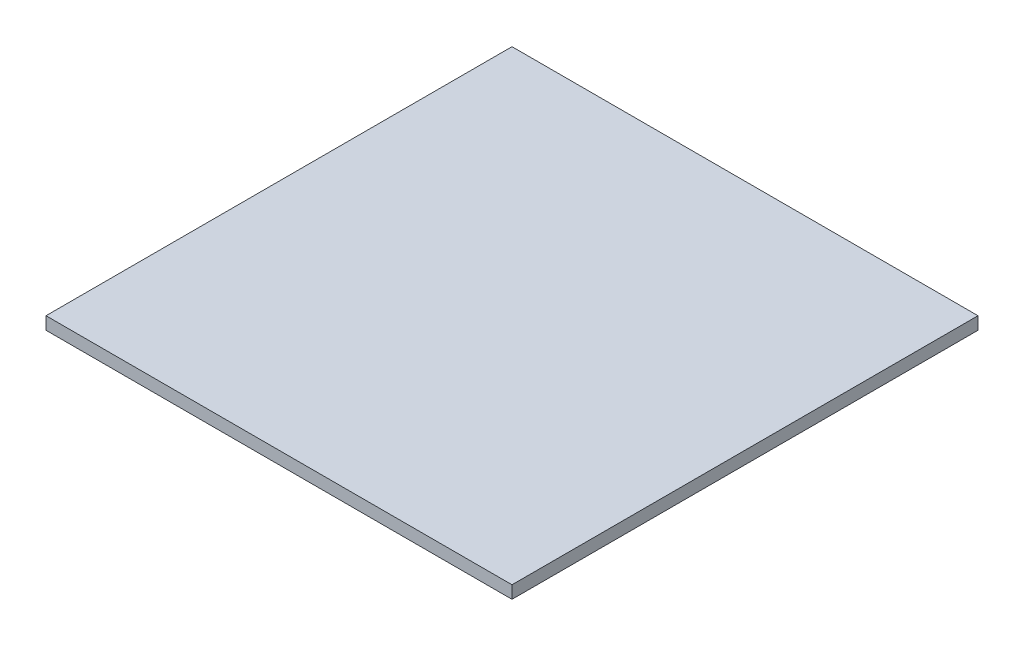
from build123d import *

# Parameters (mm, degrees)
SKETCH1_W           = 190.5
SKETCH1_H           = 190.5
BOSS_EXTRUDE1_DEPTH = 5.159375


with BuildPart() as part:
    # Sketch1 → Boss-Extrude1 (new body)
    with BuildSketch(Plane(origin=(0, 0, 0), x_dir=(1, 0, 0), z_dir=(0, 1, 0))):
        Rectangle(SKETCH1_W, SKETCH1_H)
    extrude(amount=BOSS_EXTRUDE1_DEPTH)


solid = part.part
